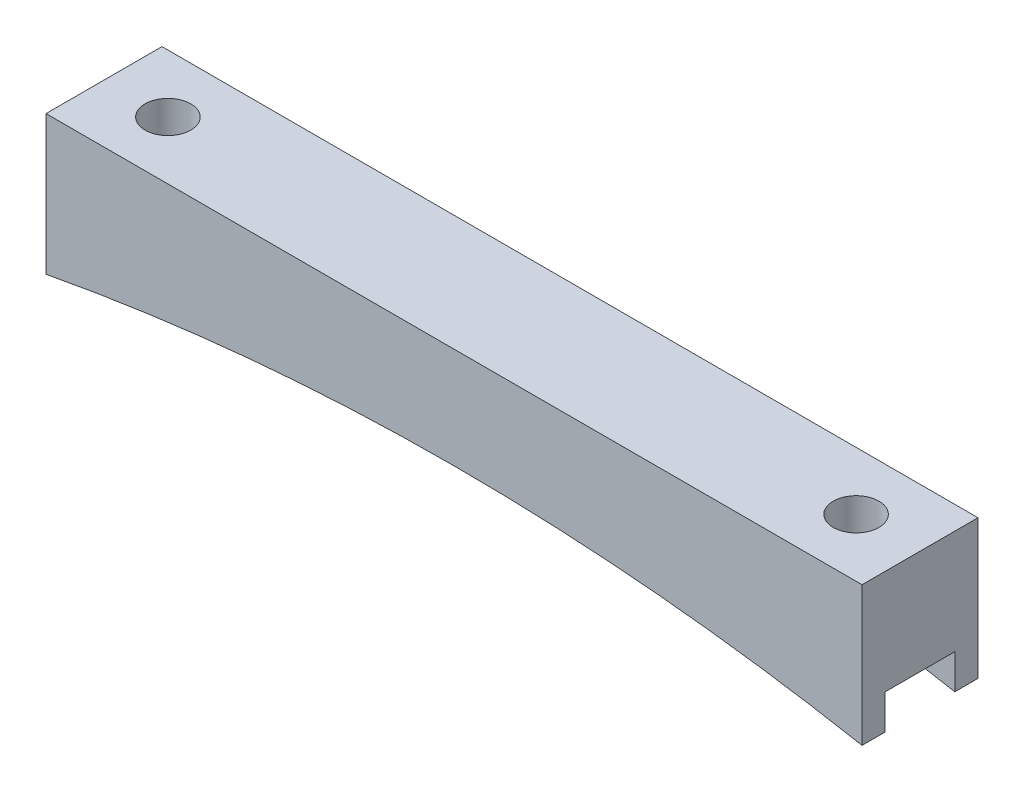
from build123d import *

# Parameters (mm, degrees)
BOSS_EXTRUDE1_DEPTH = 12.7
SKETCH2_R           = 2.5
CUT_EXTRUDE1_DEPTH  = 16.24
SKETCH3_W           = 7.62
SKETCH3_H           = 3.81
CUT_EXTRUDE2_DEPTH  = 90.3600001


with BuildPart() as part:
    # Sketch1 → Boss-Extrude1 (new body)
    with BuildSketch(Plane.XY):
        with BuildLine():
            Line((-44.68, 0), (44.68, 0))
            Line((44.68, 0), (44.68, -15.24))
            ThreePointArc((44.68, -15.24), (0, -11.067365776), (-44.68, -15.24))
            Line((-44.68, -15.24), (-44.68, 0))
        make_face()
    extrude(amount=BOSS_EXTRUDE1_DEPTH)

    # Sketch2 → Cut-Extrude1 (cut, through all)
    with BuildSketch(Plane(origin=(0, 0, 0), x_dir=(1, 0, 0), z_dir=(0, 1, 0))):
        with Locations((-37.68, -6.35)):
            Circle(SKETCH2_R)
        with Locations((37.68, -6.35)):
            Circle(SKETCH2_R)
    extrude(amount=-CUT_EXTRUDE1_DEPTH, mode=Mode.SUBTRACT)

    # Sketch3 → Cut-Extrude2 (cut, through all)
    with BuildSketch(Plane(origin=(44.68, 0, 0), x_dir=(0, 0, -1), z_dir=(1, 0, 0))):
        with Locations((-6.35, -13.335)):
            Rectangle(SKETCH3_W, SKETCH3_H)
    extrude(amount=-CUT_EXTRUDE2_DEPTH, mode=Mode.SUBTRACT)


solid = part.part
